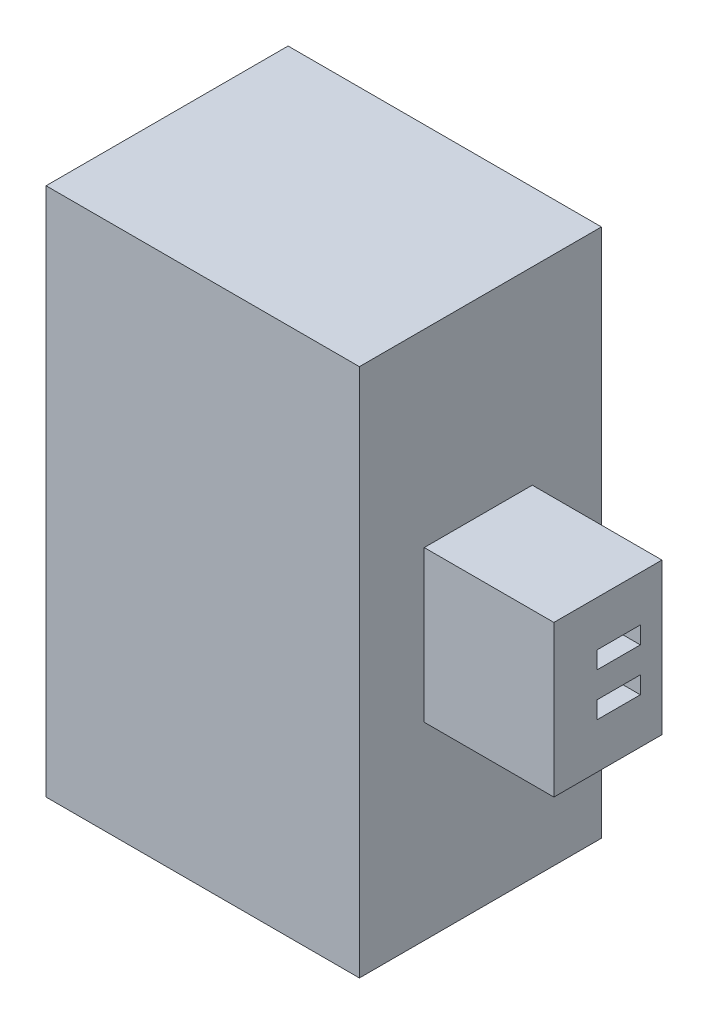
from build123d import *

# Parameters (mm, degrees)
SKETCH1_W           = 5
SKETCH1_H           = 12.25
BOSS_EXTRUDE1_DEPTH = 5.6
SKETCH3_W           = 2.5
SKETCH3_H           = 3.5
SKETCH3_W_2         = 1
SKETCH3_H_2         = 0.4
BOSS_EXTRUDE2_DEPTH = 3
SKETCH4_W           = 5.6
SKETCH4_H           = 0.75
BOSS_EXTRUDE3_DEPTH = 2.25
SKETCH5_W           = 2.25
SKETCH5_H           = 0.75
BOSS_EXTRUDE4_DEPTH = 10.75


with BuildPart() as part:
    # Sketch1 → Boss-Extrude1 (new body)
    with BuildSketch(Plane.XY):
        with Locations((2.5, 6.125)):
            Rectangle(SKETCH1_W, SKETCH1_H)
    extrude(amount=BOSS_EXTRUDE1_DEPTH)

    # Sketch3 → Boss-Extrude2 (add)
    with BuildSketch(Plane(origin=(5, 0, 0), x_dir=(0, 0, -1), z_dir=(1, 0, 0))):
        with Locations((-2.85, 6.125)):
            Rectangle(SKETCH3_W, SKETCH3_H)
        with Locations((-2.6, 6.625)):
            Rectangle(SKETCH3_W_2, SKETCH3_H_2, mode=Mode.SUBTRACT)
        with Locations((-2.6, 5.625)):
            Rectangle(SKETCH3_W_2, SKETCH3_H_2, mode=Mode.SUBTRACT)
    extrude(amount=BOSS_EXTRUDE2_DEPTH)

    # Sketch4 → Boss-Extrude3 (add)
    with BuildSketch(Plane.ZY):
        with Locations((2.8, 11.875)):
            Rectangle(SKETCH4_W, SKETCH4_H)
        with Locations((2.8, 0.375)):
            Rectangle(SKETCH4_W, SKETCH4_H)
    extrude(amount=BOSS_EXTRUDE3_DEPTH)

    # Sketch5 → Boss-Extrude4 (add)
    with BuildSketch(Plane.XZ.offset(-11.5)):
        with Locations((-1.125, 5.225)):
            Rectangle(SKETCH5_W, SKETCH5_H)
    extrude(amount=BOSS_EXTRUDE4_DEPTH)


solid = part.part
